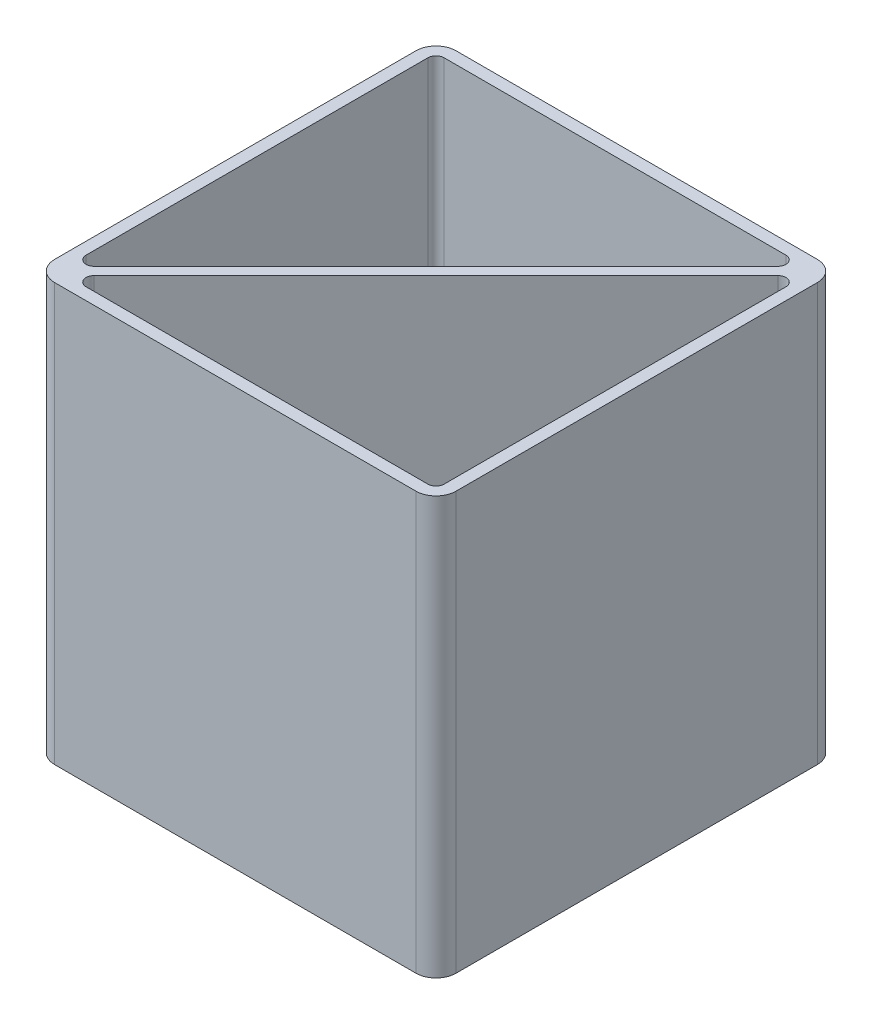
from build123d import *

# Parameters (mm, degrees)
EXTRUDE_1_DEPTH = 4
EXTRUDE_3_DEPTH = 100


with BuildPart() as part:
    # 草图1 → 凸台-拉伸1 (new body)
    with BuildSketch(Plane(origin=(0, 0, 0), x_dir=(1, 0, 0), z_dir=(0, 1, 0))):
        with BuildLine():
            ThreePointArc((50, 45), (48.535533906, 48.535533906), (45, 50))
            Line((45, 50), (-29.154564109, 50))
            Line((-29.154564109, 50), (-29.151954818, 49.997335451))
            Line((-29.151954818, 49.997335451), (-29.408928245, 49.745691122))
            Line((-29.408928245, 49.745691122), (-29.657963283, 50))
            Line((-29.657963283, 50), (-45, 50))
            ThreePointArc((-45, 50), (-48.535533906, 48.535533906), (-50, 45))
            Line((-50, 45), (-50, -45))
            ThreePointArc((-50, -45), (-48.535533906, -48.535533906), (-45, -50))
            Line((-45, -50), (45, -50))
            ThreePointArc((45, -50), (48.535533906, -48.535533906), (50, -45))
            Line((50, -45), (50, 45))
        make_face()
    extrude(amount=EXTRUDE_1_DEPTH)

    # 草图2 → 凸台-拉伸3 (add)
    with BuildSketch(Plane(origin=(0, 4, 0), x_dir=(1, 0, 0), z_dir=(0, 1, 0))):
        with BuildLine():
            Line((45, 50), (-45, 50))
            ThreePointArc((-45, 50), (-48.535533906, 48.535533906), (-50, 45))
            Line((-50, 45), (-50, -45))
            ThreePointArc((-50, -45), (-48.535533906, -48.535533906), (-45, -50))
            Line((-45, -50), (45, -50))
            ThreePointArc((45, -50), (48.535533906, -48.535533906), (50, -45))
            Line((50, -45), (50, 45))
            ThreePointArc((50, 45), (48.535533906, 48.535533906), (45, 50))
        make_face()
        with BuildLine():
            Line((-47, 45), (-47, -40.171572875))
            ThreePointArc((-47, -40.171572875), (-45.765366865, -42.01933194), (-43.585786438, -41.585786438))
            Line((-43.585786438, -41.585786438), (41.585786438, 43.585786438))
            ThreePointArc((41.585786438, 43.585786438), (42.01933194, 45.765366865), (40.171572875, 47))
            Line((40.171572875, 47), (-45, 47))
            ThreePointArc((-45, 47), (-46.414213562, 46.414213562), (-47, 45))
        make_face(mode=Mode.SUBTRACT)
        with BuildLine():
            Line((-40.171572875, -47), (45, -47))
            ThreePointArc((45, -47), (46.414213562, -46.414213562), (47, -45))
            Line((47, -45), (47, 40.171572875))
            ThreePointArc((47, 40.171572875), (45.765366865, 42.01933194), (43.585786438, 41.585786438))
            Line((43.585786438, 41.585786438), (-41.585786438, -43.585786438))
            ThreePointArc((-41.585786438, -43.585786438), (-42.01933194, -45.765366865), (-40.171572875, -47))
        make_face(mode=Mode.SUBTRACT)
    extrude(amount=EXTRUDE_3_DEPTH)


solid = part.part
